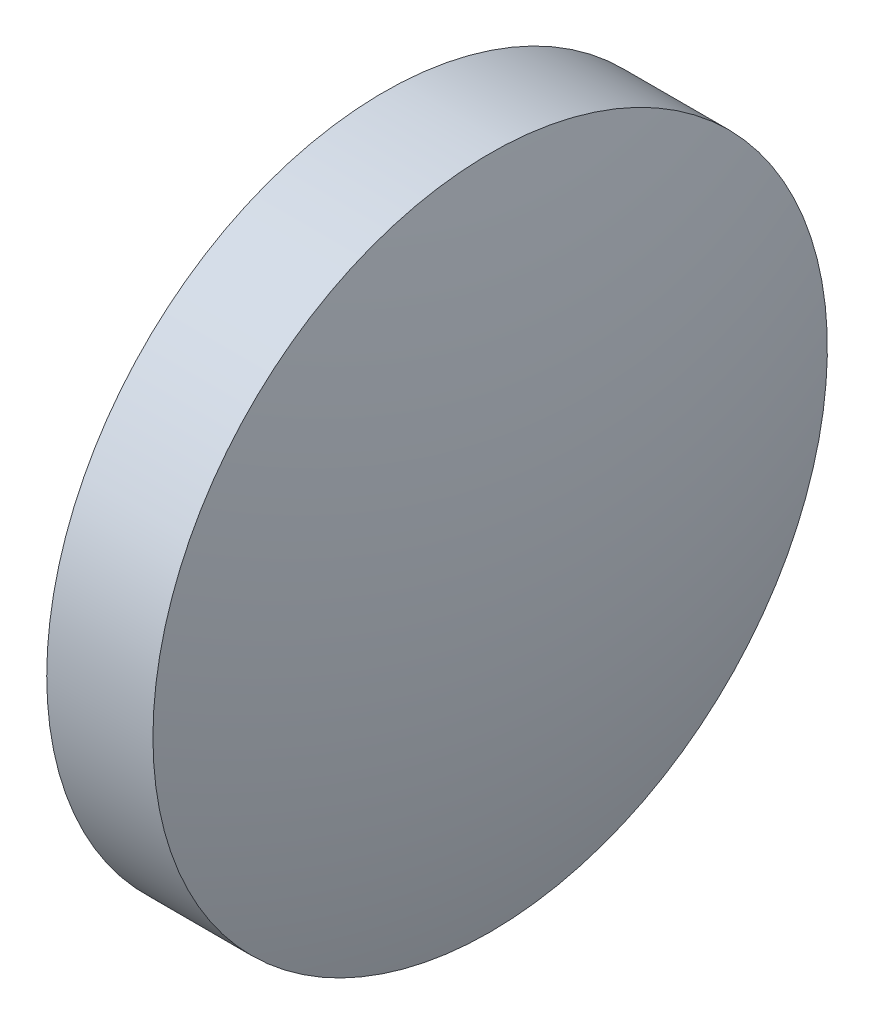
from build123d import *


with BuildPart() as part:
    # 草图1 → 旋转1 (revolve)
    with BuildSketch(Plane.XY, mode=Mode.PRIVATE) as revolve_1_sk:
        with BuildLine():
            Line((440.727312385, -5.12945932), (440.727312385, 1.22054068))
            Line((440.727312385, 1.22054068), (442.727312385, 1.22054068))
            ThreePointArc((442.727312385, 1.22054068), (443.401193641, -1.922728118), (443.627312385, -5.12945932))
            Line((443.627312385, -5.12945932), (440.727312385, -5.12945932))
        make_face()
    revolve(revolve_1_sk.sketch.rotate(Axis((438.399283895, -5.12945932, 0), (1, 0, 0)), 180), axis=Axis((438.399283895, -5.12945932, 0), (1, 0, 0)))  # turned: the seam where the file's is


solid = part.part
